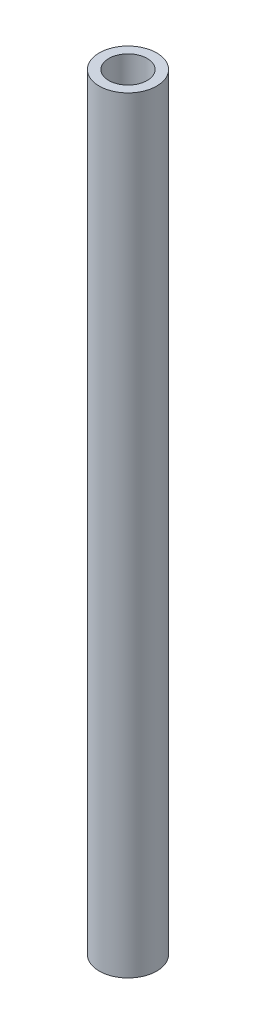
from build123d import *

# Parameters (mm, degrees)
SKETCH1_R           = 15
SKETCH1_R_2         = 10
BOSS_EXTRUDE1_DEPTH = 400


with BuildPart() as part:
    # Sketch1 → Boss-Extrude1 (new body)
    with BuildSketch(Plane(origin=(0, 0, 0), x_dir=(1, 0, 0), z_dir=(0, 1, 0))):
        Circle(SKETCH1_R)
        Circle(SKETCH1_R_2, mode=Mode.SUBTRACT)
    extrude(amount=BOSS_EXTRUDE1_DEPTH)


solid = part.part
